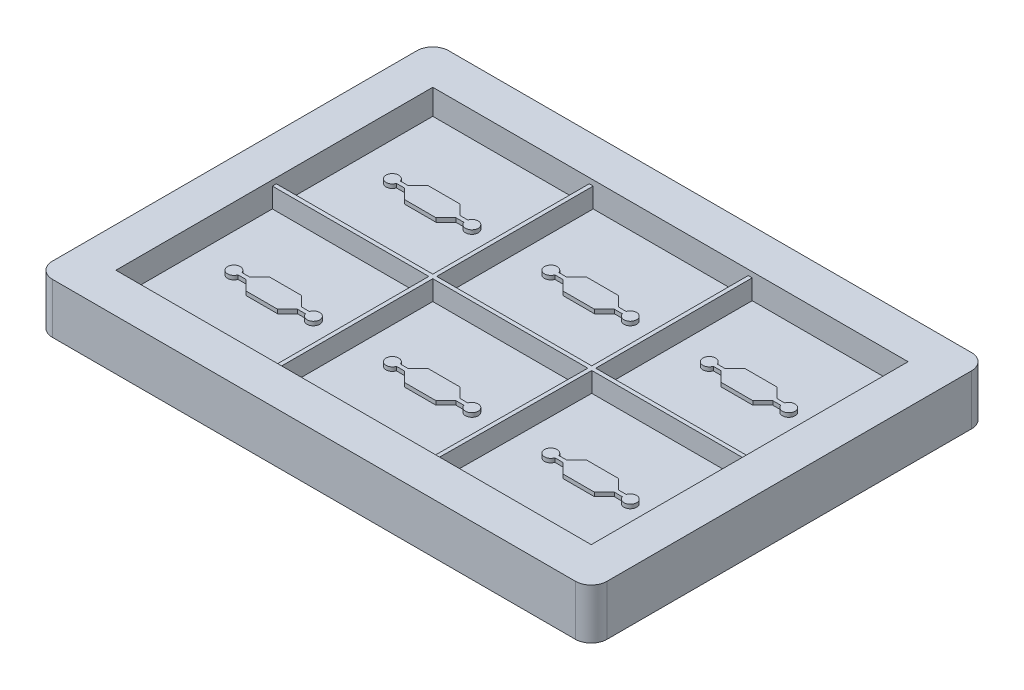
from build123d import *

# Parameters (mm, degrees)
SKETCH1_W            = 70
SKETCH1_H            = 50
BOSS_EXTRUDE1_DEPTH  = 6.35
SKETCH2_W            = 60
SKETCH2_H            = 40
CUT_EXTRUDE1_DEPTH   = 3.175
DIVIDERS_DEPTH       = 2.5
BOSS_EXTRUDE3_DEPTH  = 0.5
LPATTERN1_COUNT      = 3
LPATTERN1_PITCH      = 20
LPATTERN1_COUNT_DIR2 = 2
LPATTERN1_PITCH_DIR2 = 20
FILLET1_R            = 2


with BuildPart() as part:
    # Sketch1 → Boss-Extrude1 (new body)
    with BuildSketch(Plane(origin=(0, 0, 0), x_dir=(1, 0, 0), z_dir=(0, 1, 0))):
        Rectangle(SKETCH1_W, SKETCH1_H)
    extrude(amount=BOSS_EXTRUDE1_DEPTH)

    # Sketch2 → Cut-Extrude1 (cut)
    with BuildSketch(Plane(origin=(0, 6.35, 0), x_dir=(1, 0, 0), z_dir=(0, 1, 0))):
        Rectangle(SKETCH2_W, SKETCH2_H)
    extrude(amount=-CUT_EXTRUDE1_DEPTH, mode=Mode.SUBTRACT)

    # Sketch10 → Dividers (add)
    with BuildSketch(Plane(origin=(0, 3.175, 0), x_dir=(1, 0, 0), z_dir=(0, 1, 0))):
        Polygon((-10.25, -0.25), (-10.25, -20), (-9.75, -20), (-9.75, -0.25), (9.818560524, -0.25), (9.681439476, -20), (10.181439476, -20), (10.318560524, -0.25), (30, -0.25), (30, 0.25), (10.318560524, 0.25), (10.318560524, 20), (9.818560524, 20), (9.818560524, 0.25), (-9.75, 0.25), (-9.75, 20), (-10.25, 20), (-10.25, 0.25), (-30, 0.25), (-30, -0.25), align=None)
    extrude(amount=DIVIDERS_DEPTH)

    # Sketch11 → Boss-Extrude3 (add)
    with BuildSketch(Plane(origin=(0, 3.175, 0), x_dir=(1, 0, 0), z_dir=(0, 1, 0))):
        with BuildLine():
            Line((-24.464905709, 9.875), (-24.464905709, 10.375))
            ThreePointArc((-24.464905709, 10.375), (-26.024839917, 10.125), (-24.464905709, 9.875))
        make_face()
        Polygon((-24.464905709, 9.875), (-24.464905709, 10.375), (-23.464905709, 10.375), (-22.208630276, 11.631275433), (-18.208630276, 11.631275433), (-16.952354844, 10.375), (-15.952354844, 10.375), (-15.952354844, 9.875), (-16.952354844, 9.875), (-18.208630276, 8.618724567), (-22.208630276, 8.618724567), (-23.464905709, 9.875), align=None)
        with BuildLine():
            Line((-15.952354844, 10.375), (-15.952354844, 9.875))
            ThreePointArc((-15.952354844, 9.875), (-14.392420636, 10.125), (-15.952354844, 10.375))
        make_face()
    boss_extrude3 = extrude(amount=BOSS_EXTRUDE3_DEPTH)

    # LPattern1: Boss-Extrude3 3 × 2
    with Locations(*[(i * LPATTERN1_PITCH, 0, j * LPATTERN1_PITCH_DIR2) for i in range(LPATTERN1_COUNT) for j in range(LPATTERN1_COUNT_DIR2) if (i, j) != (0, 0)]):
        add(boss_extrude3)

    # Fillet1
    fillet1_edges = [part.edges().sort_by_distance(p)[0] for p in [
        (35, 3.175, 25),
        (-35, 3.175, 25),
        (-35, 3.175, -25),
        (35, 3.175, -25),
    ]]
    fillet(fillet1_edges, radius=FILLET1_R)


solid = part.part
